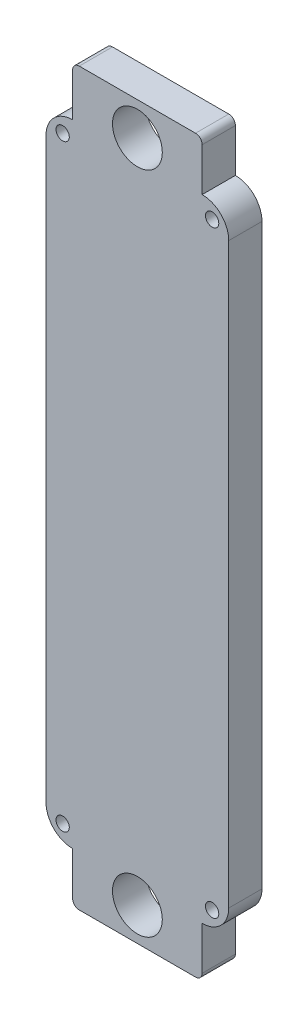
from build123d import *

# Parameters (mm, degrees)
ESBO_O1_W                = 55
ESBO_O1_H                = 190
ESBO_O1_R                = 2
RESSALTO_EXTRUS_O1_DEPTH = 10
FILETE1_R                = 8
ESBO_O3_W                = 39
ESBO_O3_H                = 15
RESSALTO_EXTRUS_O2_DEPTH = 10
ESBO_O4_R                = 7.5
CORTE_EXTRUS_O2_DEPTH    = 10
FILETE2_R                = 2


with BuildPart() as part:
    # Esboço1 → Ressalto-extrusão1 (new body)
    with BuildSketch(Plane.XY):
        Rectangle(ESBO_O1_W, ESBO_O1_H)
        with Locations((-22.5, 90)):
            Circle(ESBO_O1_R, mode=Mode.SUBTRACT)
        with Locations((22.5, 90)):
            Circle(ESBO_O1_R, mode=Mode.SUBTRACT)
        with Locations((-22.5, -90)):
            Circle(ESBO_O1_R, mode=Mode.SUBTRACT)
        with Locations((22.5, -90)):
            Circle(ESBO_O1_R, mode=Mode.SUBTRACT)
    extrude(amount=RESSALTO_EXTRUS_O1_DEPTH)

    # Filete1
    filete1_edges = [part.edges().sort_by_distance(p)[0] for p in [
        (27.5, -95, 5),
        (-27.5, -95, 5),
        (-27.5, 95, 5),
        (27.5, 95, 5),
    ]]
    fillet(filete1_edges, radius=FILETE1_R)

    # Esboço3 → Ressalto-extrusão2 (add)
    with BuildSketch(Plane.XY.offset(10)):
        with Locations((0, 102.5)):
            Rectangle(ESBO_O3_W, ESBO_O3_H)
        with Locations((0, -102.5)):
            Rectangle(ESBO_O3_W, ESBO_O3_H)
    extrude(amount=-RESSALTO_EXTRUS_O2_DEPTH)

    # Esboço4 → Corte-extrusão2 (cut)
    with BuildSketch(Plane.XY.offset(10)):
        with Locations((0, 100)):
            Circle(ESBO_O4_R)
        with Locations((0, -100)):
            Circle(ESBO_O4_R)
    extrude(amount=-CORTE_EXTRUS_O2_DEPTH, mode=Mode.SUBTRACT)

    # Filete2
    filete2_edges = [part.edges().sort_by_distance(p)[0] for p in [
        (-19.5, 110, 5),
        (19.5, 110, 5),
        (-19.5, -110, 5),
        (19.5, -110, 5),
    ]]
    fillet(filete2_edges, radius=FILETE2_R)


solid = part.part
